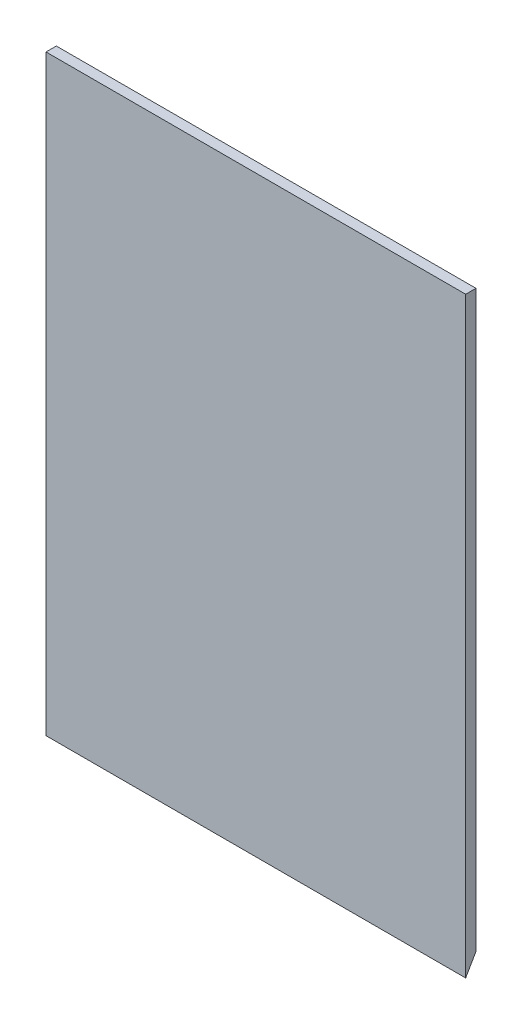
from build123d import *

# Parameters (mm, degrees)
SKETCH1_W           = 207.01
SKETCH1_H           = 292.1
BOSS_EXTRUDE1_DEPTH = 2.54
CUT_EXTRUDE3_DEPTH  = 6.35
CUT_EXTRUDE4_DEPTH  = 6.35


with BuildPart() as part:
    # Sketch1 → Boss-Extrude1 (new body, symmetric)
    with BuildSketch(Plane.XY):
        Rectangle(SKETCH1_W, SKETCH1_H)
    extrude(amount=BOSS_EXTRUDE1_DEPTH, both=True)

    # Sketch4 → Cut-Extrude3 (cut)
    with BuildSketch(Plane.ZY.offset(103.505)):
        Polygon((-2.54, -137.251181898), (2.54, -146.05), (-2.54, -146.05), align=None)
    extrude(amount=-CUT_EXTRUDE3_DEPTH, mode=Mode.SUBTRACT)

    # Sketch5 → Cut-Extrude4 (cut)
    with BuildSketch(Plane(origin=(103.505, 0, 0), x_dir=(0, 0, -1), z_dir=(1, 0, 0))):
        Polygon((2.54, -137.251181898), (-2.54, -146.05), (2.54, -146.05), align=None)
    extrude(amount=-CUT_EXTRUDE4_DEPTH, mode=Mode.SUBTRACT)


solid = part.part
